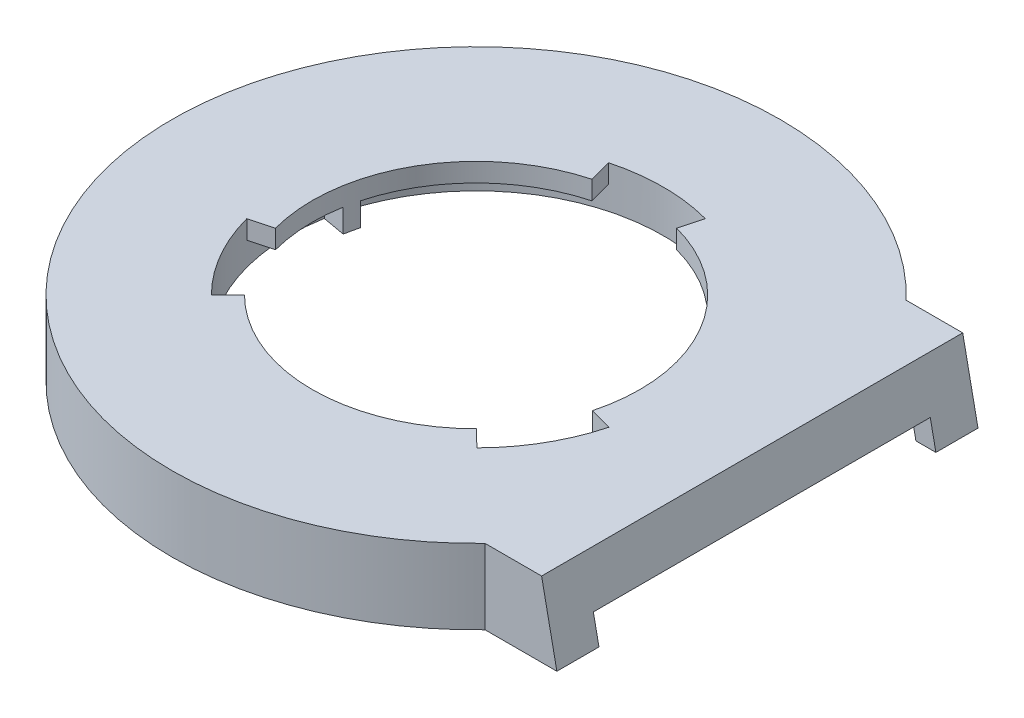
from build123d import *

# Parameters (mm, degrees)
BOSS_EXTRUDE1_DEPTH = 16
CUT_EXTRUDE1_DEPTH  = 12
SKETCH4_W           = 72
SKETCH4_H           = 5
CUT_EXTRUDE2_DEPTH  = 16
SKETCH5_R           = 35
CUT_EXTRUDE3_DEPTH  = 16
CUT_EXTRUDE4_DEPTH  = 10
SKETCH7_R           = 42
BOSS_EXTRUDE2_DEPTH = 5
SKETCH8_R           = 3.5
SKETCH8_R_2         = 1.5
BOSS_EXTRUDE3_DEPTH = 12
SKETCH13_R          = 1.5
CUT_EXTRUDE5_DEPTH  = 12
SKETCH15_W          = 14.23560612
SKETCH15_H          = 16
BOSS_EXTRUDE4_DEPTH = 90
CUT_EXTRUDE6_DEPTH  = 90
CUT_EXTRUDE11_START = -4.8
CUT_EXTRUDE11_DEPTH = 80.4
SKETCH19_W          = 72
SKETCH19_H          = 6
CUT_EXTRUDE14_DEPTH = 8.4


with BuildPart() as part:
    # Sketch1 → Boss-Extrude1 (new body)
    with BuildSketch(Plane(origin=(0, 0, 0), x_dir=(1, 0, 0), z_dir=(0, 1, 0))):
        with BuildLine():
            Line((25, -45.0001724), (25, 44.9998276))
            Line((25, 44.9998276), (46.904322999, 44.9998276))
            ThreePointArc((46.904322999, 44.9998276), (-65, 0.000238913), (46.903992196, -45.0001724))
            Line((46.903992196, -45.0001724), (25, -45.0001724))
        make_face()
        with BuildLine():
            Line((46.904322999, 44.9998276), (25, 44.9998276))
            Line((25, 44.9998276), (25, -45.0001724))
            Line((25, -45.0001724), (46.903992196, -45.0001724))
            ThreePointArc((46.903992196, -45.0001724), (60.306548122, -24.251190767), (65, 0))
            ThreePointArc((65, 0), (60.306637259, 24.250969105), (46.904322999, 44.9998276))
        make_face()
        with BuildLine():
            Line((69, 44.9998276), (46.904322999, 44.9998276))
            ThreePointArc((46.904322999, 44.9998276), (60.306637259, 24.250969105), (65, 0))
            ThreePointArc((65, 0), (60.306548122, -24.251190767), (46.903992196, -45.0001724))
            Line((46.903992196, -45.0001724), (69, -45.0001724))
            Line((69, -45.0001724), (69, 44.9998276))
        make_face()
    extrude(amount=BOSS_EXTRUDE1_DEPTH)

    # Sketch3 → Cut-Extrude1 (cut)
    with BuildSketch(Plane.XZ):
        with BuildLine():
            Line((13.648760289, 40.2001724), (44.541510291, 40.2001724))
            ThreePointArc((44.541510291, 40.2001724), (-60, -0.000232232), (44.541821482, -40.1998276))
            Line((44.541821482, -40.1998276), (13.648760289, -40.1998276))
            Line((13.648760289, -40.1998276), (13.648760289, 40.2001724))
        make_face()
        with BuildLine():
            ThreePointArc((60, 0), (56.002190214, 21.53496439), (44.541510291, 40.2001724))
            Line((44.541510291, 40.2001724), (13.648760289, 40.2001724))
            Line((13.648760289, 40.2001724), (13.648760289, -40.1998276))
            Line((13.648760289, -40.1998276), (44.541821482, -40.1998276))
            ThreePointArc((44.541821482, -40.1998276), (56.002273565, -21.534747631), (60, 0))
        make_face()
        with BuildLine():
            Line((64, -40.1998276), (64, 40.2001724))
            Line((64, 40.2001724), (44.541510291, 40.2001724))
            ThreePointArc((44.541510291, 40.2001724), (56.002190214, 21.53496439), (60, 0))
            ThreePointArc((60, 0), (56.002273565, -21.534747631), (44.541821482, -40.1998276))
            Line((44.541821482, -40.1998276), (64, -40.1998276))
        make_face()
    extrude(amount=-CUT_EXTRUDE1_DEPTH, mode=Mode.SUBTRACT)

    # Sketch4 → Cut-Extrude2 (cut)
    with BuildSketch(Plane(origin=(69, 0, 0), x_dir=(0, 0, -1), z_dir=(1, 0, 0))):
        with Locations((-0.0001724, 2.5)):
            Rectangle(SKETCH4_W, SKETCH4_H)
    extrude(amount=-CUT_EXTRUDE2_DEPTH, mode=Mode.SUBTRACT)

    # Sketch5 → Cut-Extrude3 (cut)
    with BuildSketch(Plane(origin=(0, 16, 0), x_dir=(1, 0, 0), z_dir=(0, 1, 0))):
        Circle(SKETCH5_R)
    extrude(amount=-CUT_EXTRUDE3_DEPTH, mode=Mode.SUBTRACT)

    # Sketch6 → Cut-Extrude4 (cut)
    with BuildSketch(Plane(origin=(0, 16, 0), x_dir=(1, 0, 0), z_dir=(0, 1, 0))):
        with BuildLine():
            Line((-28.284271247, -28.284271247), (-24.748737342, -24.748737342))
            ThreePointArc((-24.748737342, -24.748737342), (-27.76736691, -21.306650015), (-30.310889132, -17.5))
            Line((-30.310889132, -17.5), (-34.641016151, -20))
            ThreePointArc((-34.641016151, -20), (-31.734133612, -24.35045716), (-28.284271247, -28.284271247))
        make_face()
        with BuildLine():
            Line((-34.641016151, -20), (-30.310889132, -17.5))
            ThreePointArc((-30.310889132, -17.5), (-32.335783638, -13.393920133), (-33.80740392, -9.058666579))
            Line((-33.80740392, -9.058666579), (-38.637033052, -10.352761804))
            ThreePointArc((-38.637033052, -10.352761804), (-36.9551813, -15.307337295), (-34.641016151, -20))
        make_face()
        with BuildLine():
            Line((-10.352761804, 38.637033052), (-9.058666579, 33.80740392))
            ThreePointArc((-9.058666579, 33.80740392), (0, 35), (9.058666579, 33.80740392))
            Line((9.058666579, 33.80740392), (10.352761804, 38.637033052))
            ThreePointArc((10.352761804, 38.637033052), (0, 40), (-10.352761804, 38.637033052))
        make_face()
        with BuildLine():
            ThreePointArc((33.831018509, -8.970071717), (32.370760151, -13.309165535), (30.356629112, -17.420535841))
            Line((30.356629112, -17.420535841), (34.693290413, -19.909183818))
            ThreePointArc((34.693290413, -19.909183818), (36.995154458, -15.210474897), (38.664021154, -10.251510534))
            Line((38.664021154, -10.251510534), (33.831018509, -8.970071717))
        make_face()
        with BuildLine():
            ThreePointArc((30.356629112, -17.420535841), (27.823087732, -21.233835948), (24.813485607, -24.683819236))
            Line((24.813485607, -24.683819236), (28.358269265, -28.210079126))
            ThreePointArc((28.358269265, -28.210079126), (31.79781455, -24.267241084), (34.693290413, -19.909183818))
            Line((34.693290413, -19.909183818), (30.356629112, -17.420535841))
        make_face()
    extrude(amount=-CUT_EXTRUDE4_DEPTH, mode=Mode.SUBTRACT)

    # Sketch7 → Boss-Extrude2 (add)
    with BuildSketch(Plane.XZ.offset(-12)):
        Circle(SKETCH7_R)
        with BuildLine():
            ThreePointArc((-28.284271247, 28.284271247), (-10.352761804, 38.637033052), (10.352761804, 38.637033052))
            Line((10.352761804, 38.637033052), (9.058666579, 33.80740392))
            ThreePointArc((9.058666579, 33.80740392), (10.524702983, 33.380093276), (11.970705016, 32.889241728))
            Line((11.970705016, 32.889241728), (13.680805733, 37.587704831))
            ThreePointArc((13.680805733, 37.587704831), (21.53615385, 33.707478063), (28.358269265, 28.210079126))
            ThreePointArc((28.358269265, 28.210079126), (34.693290413, 19.909183818), (38.664021154, 10.251510534))
            ThreePointArc((38.664021154, 10.251510534), (38.623439557, -10.40336084), (28.284271247, -28.284271247))
            Line((28.284271247, -28.284271247), (24.748737342, -24.748737342))
            ThreePointArc((24.748737342, -24.748737342), (23.645657267, -25.804706788), (22.497566339, -26.811555509))
            Line((22.497566339, -26.811555509), (25.711504387, -30.641777725))
            ThreePointArc((25.711504387, -30.641777725), (18.469944529, -35.480433327), (10.352761804, -38.637033052))
            ThreePointArc((10.352761804, -38.637033052), (0, -40), (-10.352761804, -38.637033052))
            ThreePointArc((-10.352761804, -38.637033052), (-28.284271247, -28.284271247), (-38.637033052, -10.352761804))
            Line((-38.637033052, -10.352761804), (-33.80740392, -9.058666579))
            ThreePointArc((-33.80740392, -9.058666579), (-34.170360249, -7.575386488), (-34.468271355, -6.077686218))
            Line((-34.468271355, -6.077686218), (-39.39231012, -6.945927107))
            ThreePointArc((-39.39231012, -6.945927107), (-39.961928863, 1.744775495), (-38.637033052, 10.352761804))
            ThreePointArc((-38.637033052, 10.352761804), (-34.641016151, 20), (-28.284271247, 28.284271247))
        make_face(mode=Mode.SUBTRACT)
    extrude(amount=BOSS_EXTRUDE2_DEPTH)

    # Sketch8 → Boss-Extrude3 (add)
    with BuildSketch(Plane.XZ.offset(-12)):
        with Locations((-25.212285918, 54.445758685)):
            Circle(SKETCH8_R)
        with Locations((-25.212285918, 54.445758685)):
            Circle(SKETCH8_R_2, mode=Mode.SUBTRACT)
        with Locations((-25, -54.543560573)):
            Circle(SKETCH8_R)
        with Locations((-25, -54.543560573)):
            Circle(SKETCH8_R_2, mode=Mode.SUBTRACT)
        with Locations((44.541510291, 40.2001724)):
            Circle(SKETCH8_R)
        with Locations((44.541510291, 40.2001724)):
            Circle(SKETCH8_R_2, mode=Mode.SUBTRACT)
        with Locations((44.541821482, -40.1998276)):
            Circle(SKETCH8_R)
        with Locations((44.541821482, -40.1998276)):
            Circle(SKETCH8_R_2, mode=Mode.SUBTRACT)
    extrude(amount=BOSS_EXTRUDE3_DEPTH)

    # Sketch13 → Cut-Extrude5 (cut)
    with BuildSketch(Plane.XZ.offset(-12)):
        with Locations((44.541510291, 40.2001724)):
            Circle(SKETCH13_R)
        with Locations((-25.212285918, 54.445758685)):
            Circle(SKETCH13_R)
        with Locations((-25, -54.543560573)):
            Circle(SKETCH13_R)
        with Locations((44.541821482, -40.1998276)):
            Circle(SKETCH13_R)
    extrude(amount=CUT_EXTRUDE5_DEPTH, mode=Mode.SUBTRACT)

    # Sketch15 → Boss-Extrude4 (add)
    with BuildSketch(Plane.XY.offset(45.0001724)):
        with Locations((61.88219694, 8)):
            Rectangle(SKETCH15_W, SKETCH15_H)
    extrude(amount=-BOSS_EXTRUDE4_DEPTH)

    # Sketch14 → Cut-Extrude6 (cut)
    with BuildSketch(Plane(origin=(0, 0, -44.9998276), x_dir=(-1, 0, 0), z_dir=(0, 0, -1))):
        Polygon((-69, 16), (-59, 16), (-69, -33), align=None)
    extrude(amount=-CUT_EXTRUDE6_DEPTH, mode=Mode.SUBTRACT)

    # Sketch17 → Cut-Extrude11 (cut)
    with BuildSketch(Plane.XY.offset(45.0001724).offset(CUT_EXTRUDE11_START)):
        Polygon((58.000000002, 0), (54.73469388, 0), (54.73469388, 12), (55.551020411, 12), align=None)
    extrude(amount=-CUT_EXTRUDE11_DEPTH, mode=Mode.SUBTRACT)

    # Sketch19 → Cut-Extrude14 (cut)
    with BuildSketch(Plane(origin=(59.775689724, 12.199120352, 0), x_dir=(0, 0, -1), z_dir=(0.979804059, 0.199960012, 0))):
        with Locations((-0.0001724, -9.450571359)):
            Rectangle(SKETCH19_W, SKETCH19_H)
    extrude(amount=-CUT_EXTRUDE14_DEPTH, mode=Mode.SUBTRACT)


solid = part.part
